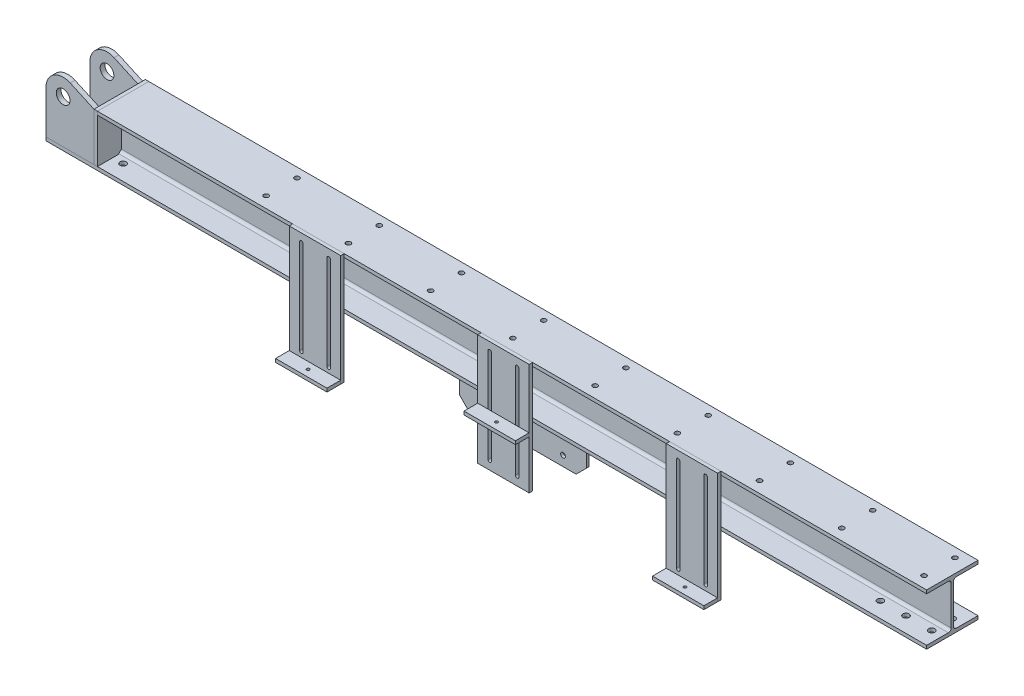
from build123d import *

# Parameters (mm, degrees)
H_HW150_1_DEPTH              = 2570
CUT_EXTRUDE_2_REACH          = 2577.466
SKETCH_18_R                  = 9
SKETCH_19_W                  = 370
SKETCH_19_H                  = 8
EXTRUDE_3_DEPTH              = 140
CHAMFER_1_SIZE               = 30
SKETCH_20_R                  = 7
CUT_EXTRUDE_3_DEPTH          = 8
CUT_EXTRUDE_4_DEPTH          = 75
EXTRUDE_4_DEPTH              = 10
EXTRUDE_5_DEPTH              = 14
EXTRUDE_6_DEPTH              = 14
SKETCH_116_R                 = 20
CUT_EXTRUDE_5_DEPTH          = 14
SKETCH_117_R                 = 20
CUT_EXTRUDE_6_DEPTH          = 14
EXTRUDE_7_DEPTH              = 6
PATTERN_LINEAR_1_COUNT       = 4
PATTERN_LINEAR_1_PITCH       = 570
SKETCH_119_R                 = 7
CUT_EXTRUDE_7_DEPTH          = 10
SKETCH_120_W                 = 150
SKETCH_120_H                 = 325
EXTRUDE_8_DEPTH              = 10
PATTERN_LINEAR_2_COUNT       = 3
PATTERN_LINEAR_2_PITCH       = 550
SKETCH_121_W                 = 150
SKETCH_121_H                 = 10
EXTRUDE_9_DEPTH              = 40
SKETCH_122_W                 = 150
SKETCH_122_H                 = 10
EXTRUDE_10_DEPTH             = 40
SKETCH_123_W                 = 150
SKETCH_123_H                 = 10
EXTRUDE_11_DEPTH             = 40
EXTRUDE_12_DEPTH             = 3
PATTERN_LINEAR_3_COUNT       = 3
PATTERN_LINEAR_3_PITCH       = 550
SKETCH_125_W                 = 4.25
SKETCH_125_H                 = 10.001
SKETCH_126_W                 = 4.25
SKETCH_126_H                 = 10.001
HOLE_WIZARD_M10_2_AT_2_COUNT = 2
HOLE_WIZARD_M10_2_AT_2_PITCH = 1100


with BuildPart() as part:
    # 草图111 → H型钢 HW150(1) (new body)
    with BuildSketch(Plane(origin=(0, 0, 0), x_dir=(0, 0, -1), z_dir=(1, 0, 0))):
        with BuildLine():
            Line((-75, -75), (75, -75))
            Line((75, -75), (75, -65))
            Line((75, -65), (11.5, -65))
            ThreePointArc((11.5, -65), (5.843145751, -62.656854249), (3.5, -57))
            Line((3.5, -57), (3.5, 57))
            ThreePointArc((3.5, 57), (5.843145751, 62.656854249), (11.5, 65))
            Line((11.5, 65), (75, 65))
            Line((75, 65), (75, 75))
            Line((75, 75), (-75, 75))
            Line((-75, 75), (-75, 65))
            Line((-75, 65), (-11.5, 65))
            ThreePointArc((-11.5, 65), (-5.843145751, 62.656854249), (-3.5, 57))
            Line((-3.5, 57), (-3.5, -57))
            ThreePointArc((-3.5, -57), (-5.843145751, -62.656854249), (-11.5, -65))
            Line((-11.5, -65), (-75, -65))
            Line((-75, -65), (-75, -75))
        make_face()
    extrude(amount=H_HW150_1_DEPTH)

    # 草图18 → 切除-拉伸2 (cut, up to next)
    with BuildSketch(Plane.XZ.offset(75), mode=Mode.PRIVATE) as cut_extrude_2_sk1:
        with Locations(Location((30, 30, 0), (0, 0, 270))):
            Circle(SKETCH_18_R)
    cut_extrude_2_tool1 = extrude(cut_extrude_2_sk1.sketch, amount=-CUT_EXTRUDE_2_REACH, mode=Mode.PRIVATE) & part.part
    # 草图18 → 切除-拉伸2 (cut, up to next)
    with BuildSketch(Plane.XZ.offset(75), mode=Mode.PRIVATE) as cut_extrude_2_sk2:
        with Locations(Location((30, -30, 0), (0, 0, 270))):
            Circle(SKETCH_18_R)
    cut_extrude_2_tool2 = extrude(cut_extrude_2_sk2.sketch, amount=-CUT_EXTRUDE_2_REACH, mode=Mode.PRIVATE) & part.part
    # 草图18 → 切除-拉伸2 (cut, up to next)
    with BuildSketch(Plane.XZ.offset(75), mode=Mode.PRIVATE) as cut_extrude_2_sk3:
        with Locations(Location((105, -30, 0), (0, 0, 270))):
            Circle(SKETCH_18_R)
    cut_extrude_2_tool3 = extrude(cut_extrude_2_sk3.sketch, amount=-CUT_EXTRUDE_2_REACH, mode=Mode.PRIVATE) & part.part
    # 草图18 → 切除-拉伸2 (cut, up to next)
    with BuildSketch(Plane.XZ.offset(75), mode=Mode.PRIVATE) as cut_extrude_2_sk4:
        with Locations(Location((105, 30, 0), (0, 0, 270))):
            Circle(SKETCH_18_R)
    cut_extrude_2_tool4 = extrude(cut_extrude_2_sk4.sketch, amount=-CUT_EXTRUDE_2_REACH, mode=Mode.PRIVATE) & part.part
    # 草图18 → 切除-拉伸2 (cut, up to next)
    with BuildSketch(Plane.XZ.offset(75), mode=Mode.PRIVATE) as cut_extrude_2_sk5:
        with Locations(Location((180, 30, 0), (0, 0, 270))):
            Circle(SKETCH_18_R)
    cut_extrude_2_tool5 = extrude(cut_extrude_2_sk5.sketch, amount=-CUT_EXTRUDE_2_REACH, mode=Mode.PRIVATE) & part.part
    # 草图18 → 切除-拉伸2 (cut, up to next)
    with BuildSketch(Plane.XZ.offset(75), mode=Mode.PRIVATE) as cut_extrude_2_sk6:
        with Locations(Location((180, -30, 0), (0, 0, 270))):
            Circle(SKETCH_18_R)
    cut_extrude_2_tool6 = extrude(cut_extrude_2_sk6.sketch, amount=-CUT_EXTRUDE_2_REACH, mode=Mode.PRIVATE) & part.part
    # 草图18 → 切除-拉伸2 (cut, up to next)
    with BuildSketch(Plane.XZ.offset(75), mode=Mode.PRIVATE) as cut_extrude_2_sk7:
        with Locations(Location((2390, 30, 0), (0, 0, 270))):
            Circle(SKETCH_18_R)
    cut_extrude_2_tool7 = extrude(cut_extrude_2_sk7.sketch, amount=-CUT_EXTRUDE_2_REACH, mode=Mode.PRIVATE) & part.part
    # 草图18 → 切除-拉伸2 (cut, up to next)
    with BuildSketch(Plane.XZ.offset(75), mode=Mode.PRIVATE) as cut_extrude_2_sk8:
        with Locations(Location((2465, 30, 0), (0, 0, 270))):
            Circle(SKETCH_18_R)
    cut_extrude_2_tool8 = extrude(cut_extrude_2_sk8.sketch, amount=-CUT_EXTRUDE_2_REACH, mode=Mode.PRIVATE) & part.part
    # 草图18 → 切除-拉伸2 (cut, up to next)
    with BuildSketch(Plane.XZ.offset(75), mode=Mode.PRIVATE) as cut_extrude_2_sk9:
        with Locations(Location((2540, 30, 0), (0, 0, 270))):
            Circle(SKETCH_18_R)
    cut_extrude_2_tool9 = extrude(cut_extrude_2_sk9.sketch, amount=-CUT_EXTRUDE_2_REACH, mode=Mode.PRIVATE) & part.part
    # 草图18 → 切除-拉伸2 (cut, up to next)
    with BuildSketch(Plane.XZ.offset(75), mode=Mode.PRIVATE) as cut_extrude_2_sk10:
        with Locations(Location((2540, -30, 0), (0, 0, 270))):
            Circle(SKETCH_18_R)
    cut_extrude_2_tool10 = extrude(cut_extrude_2_sk10.sketch, amount=-CUT_EXTRUDE_2_REACH, mode=Mode.PRIVATE) & part.part
    # 草图18 → 切除-拉伸2 (cut, up to next)
    with BuildSketch(Plane.XZ.offset(75), mode=Mode.PRIVATE) as cut_extrude_2_sk11:
        with Locations(Location((2465, -30, 0), (0, 0, 270))):
            Circle(SKETCH_18_R)
    cut_extrude_2_tool11 = extrude(cut_extrude_2_sk11.sketch, amount=-CUT_EXTRUDE_2_REACH, mode=Mode.PRIVATE) & part.part
    # 草图18 → 切除-拉伸2 (cut, up to next)
    with BuildSketch(Plane.XZ.offset(75), mode=Mode.PRIVATE) as cut_extrude_2_sk12:
        with Locations(Location((2390, -30, 0), (0, 0, 270))):
            Circle(SKETCH_18_R)
    cut_extrude_2_tool12 = extrude(cut_extrude_2_sk12.sketch, amount=-CUT_EXTRUDE_2_REACH, mode=Mode.PRIVATE) & part.part
    add(cut_extrude_2_tool1.solids().sort_by_distance((30, -75, 30))[0], mode=Mode.SUBTRACT)
    add(cut_extrude_2_tool2.solids().sort_by_distance((30, -75, -30))[0], mode=Mode.SUBTRACT)
    add(cut_extrude_2_tool3.solids().sort_by_distance((105, -75, -30))[0], mode=Mode.SUBTRACT)
    add(cut_extrude_2_tool4.solids().sort_by_distance((105, -75, 30))[0], mode=Mode.SUBTRACT)
    add(cut_extrude_2_tool5.solids().sort_by_distance((180, -75, 30))[0], mode=Mode.SUBTRACT)
    add(cut_extrude_2_tool6.solids().sort_by_distance((180, -75, -30))[0], mode=Mode.SUBTRACT)
    add(cut_extrude_2_tool7.solids().sort_by_distance((2390, -75, 30))[0], mode=Mode.SUBTRACT)
    add(cut_extrude_2_tool8.solids().sort_by_distance((2465, -75, 30))[0], mode=Mode.SUBTRACT)
    add(cut_extrude_2_tool9.solids().sort_by_distance((2540, -75, 30))[0], mode=Mode.SUBTRACT)
    add(cut_extrude_2_tool10.solids().sort_by_distance((2540, -75, -30))[0], mode=Mode.SUBTRACT)
    add(cut_extrude_2_tool11.solids().sort_by_distance((2465, -75, -30))[0], mode=Mode.SUBTRACT)
    add(cut_extrude_2_tool12.solids().sort_by_distance((2390, -75, -30))[0], mode=Mode.SUBTRACT)

    # 草图112 → 切除-拉伸4 (cut, symmetric)
    with BuildSketch(Plane.XY):
        Polygon((0, 75), (150, 75), (150, 60), (10, -65), (0, -65), align=None)
    extrude(amount=CUT_EXTRUDE_4_DEPTH, both=True, mode=Mode.SUBTRACT)

    # 草图119 → 切除-拉伸7 (cut)
    with BuildSketch(Plane(origin=(0, 75, 0), x_dir=(1, 0, 0), z_dir=(0, 1, 0))):
        with Locations(Location((2530, -42.5, 0), (0, 0, 270))):
            Circle(SKETCH_119_R)
        with Locations(Location((2530, 47.5, 0), (0, 0, 270))):
            Circle(SKETCH_119_R)
        with Locations(Location((2290, -42.5, 0), (0, 0, 270))):
            Circle(SKETCH_119_R)
        with Locations(Location((2290, 47.5, 0), (0, 0, 270))):
            Circle(SKETCH_119_R)
        with Locations(Location((2050, -42.5, 0), (0, 0, 270))):
            Circle(SKETCH_119_R)
        with Locations(Location((2050, 47.5, 0), (0, 0, 270))):
            Circle(SKETCH_119_R)
        with Locations(Location((1810, -42.5, 0), (0, 0, 270))):
            Circle(SKETCH_119_R)
        with Locations(Location((1810, 47.5, 0), (0, 0, 270))):
            Circle(SKETCH_119_R)
        with Locations(Location((1570, -42.5, 0), (0, 0, 270))):
            Circle(SKETCH_119_R)
        with Locations(Location((1570, 47.5, 0), (0, 0, 270))):
            Circle(SKETCH_119_R)
        with Locations(Location((1330, -42.5, 0), (0, 0, 270))):
            Circle(SKETCH_119_R)
        with Locations(Location((1330, 47.5, 0), (0, 0, 270))):
            Circle(SKETCH_119_R)
        with Locations(Location((1090, -42.5, 0), (0, 0, 270))):
            Circle(SKETCH_119_R)
        with Locations(Location((1090, 47.5, 0), (0, 0, 270))):
            Circle(SKETCH_119_R)
        with Locations(Location((850, -42.5, 0), (0, 0, 270))):
            Circle(SKETCH_119_R)
        with Locations(Location((850, 47.5, 0), (0, 0, 270))):
            Circle(SKETCH_119_R)
        with Locations(Location((610, -42.5, 0), (0, 0, 270))):
            Circle(SKETCH_119_R)
        with Locations(Location((610, 47.5, 0), (0, 0, 270))):
            Circle(SKETCH_119_R)
    extrude(amount=-CUT_EXTRUDE_7_DEPTH, mode=Mode.SUBTRACT)


with BuildPart() as body_2:
    # 草图19 → 凸台-拉伸3 (new body)
    with BuildSketch(Plane.XZ.offset(75)):
        with Locations((1321, 0)):
            Rectangle(SKETCH_19_W, SKETCH_19_H)
    extrude(amount=EXTRUDE_3_DEPTH)

    # 倒角1
    chamfer_1_edges = [body_2.edges().sort_by_distance(p)[0] for p in [
        (1506, -215, 0),
        (1136, -215, 0),
    ]]
    chamfer(chamfer_1_edges, length=CHAMFER_1_SIZE)

    # 草图20 → 切除-拉伸3 (cut)
    with BuildSketch(Plane(origin=(0, 0, -4), x_dir=(-1, 0, 0), z_dir=(0, 0, -1))):
        with Locations(Location((-1401, -115, 0), (0, 0, 90))):
            Circle(SKETCH_20_R)
        with Locations(Location((-1241, -115, 0), (0, 0, 90))):
            Circle(SKETCH_20_R)
        with Locations(Location((-1437.939889059, -185.960866654, 0), (0, 0, 90))):
            Circle(SKETCH_20_R)
        with Locations(Location((-1204.060110941, -185.960866654, 0), (0, 0, 90))):
            Circle(SKETCH_20_R)
    extrude(amount=-CUT_EXTRUDE_3_DEPTH, mode=Mode.SUBTRACT)


with BuildPart() as body_3:
    # 草图113 → 凸台-拉伸4 (new body)
    with BuildSketch(Plane.ZY.offset(-150)):
        Polygon((-75, 75), (75, 75), (75, -65), (14, -65), (4, -55), (4, 60.5), (-4, 60.5), (-4, -55), (-14, -65), (-75, -65), align=None)
    extrude(amount=EXTRUDE_4_DEPTH)


with BuildPart() as body_4:
    # 草图114 → 凸台-拉伸5 (new body)
    with BuildSketch(Plane.XY.offset(75)):
        with BuildLine():
            Line((0, -65), (0, 61))
            ThreePointArc((0, 61), (22.934192483, 103.040956976), (70.697682537, 106.514897974))
            Line((70.697682537, 106.514897974), (140, 75))
            Line((140, 75), (140, -65))
            Line((140, -65), (0, -65))
        make_face()
    extrude(amount=-EXTRUDE_5_DEPTH)

    # 草图116 → 切除-拉伸5 (cut)
    with BuildSketch(Plane.XY.offset(75)):
        with Locations((50, 61.5)):
            Circle(SKETCH_116_R)
    extrude(amount=-CUT_EXTRUDE_5_DEPTH, mode=Mode.SUBTRACT)


with BuildPart() as body_5:
    # 草图115 → 凸台-拉伸6 (new body)
    with BuildSketch(Plane(origin=(0, 0, -67), x_dir=(-1, 0, 0), z_dir=(0, 0, -1))):
        with BuildLine():
            Line((-140, -65), (0, -65))
            Line((0, -65), (0, 61))
            ThreePointArc((0, 61), (-22.934192483, 103.040956976), (-70.697682537, 106.514897974))
            Line((-70.697682537, 106.514897974), (-140, 75))
            Line((-140, 75), (-140, -65))
        make_face()
    extrude(amount=-EXTRUDE_6_DEPTH)

    # 草图117 → 切除-拉伸6 (cut)
    with BuildSketch(Plane(origin=(0, 0, -67), x_dir=(-1, 0, 0), z_dir=(0, 0, -1))):
        with Locations((-50, 61)):
            Circle(SKETCH_117_R)
    extrude(amount=-CUT_EXTRUDE_6_DEPTH, mode=Mode.SUBTRACT)


with BuildPart() as body_6:
    # 草图118 → 凸台-拉伸7 (new body)
    with BuildSketch(Plane(origin=(2420, 0, 0), x_dir=(0, 0, -1), z_dir=(1, 0, 0))):
        Polygon((13.5, 65), (73.5, 65), (73.5, -65), (13.5, -65), (3.5, -55), (3.5, 55), align=None)
    extrude_7 = extrude(amount=EXTRUDE_7_DEPTH)


with BuildPart() as pattern_linear_1_1:
    # 阵列(线性)1: 凸台-拉伸7 ×4
    with Locations(*[(-i * PATTERN_LINEAR_1_PITCH, 0, 0) for i in range(1, PATTERN_LINEAR_1_COUNT)]):
        add(extrude_7)


with BuildPart() as body_10:
    # 草图120 → 凸台-拉伸8 (new body)
    with BuildSketch(Plane.XY.offset(75)):
        with Locations((1895, -87.5)):
            Rectangle(SKETCH_120_W, SKETCH_120_H)
        with BuildLine():
            Line((1850, -225), (1850, 50))
            ThreePointArc((1850, 50), (1855, 55), (1860, 50))
            Line((1860, 50), (1860, -225))
            ThreePointArc((1860, -225), (1855, -230), (1850, -225))
        make_face(mode=Mode.SUBTRACT)
        with BuildLine():
            Line((1930, 50), (1930, -225))
            ThreePointArc((1930, -225), (1935, -230), (1940, -225))
            Line((1940, -225), (1940, 50))
            ThreePointArc((1940, 50), (1935, 55), (1930, 50))
        make_face(mode=Mode.SUBTRACT)
    extrude_8 = extrude(amount=EXTRUDE_8_DEPTH)


with BuildPart() as pattern_linear_2_1:
    # 阵列(线性)2: 凸台-拉伸8 ×3
    with Locations(*[(-i * PATTERN_LINEAR_2_PITCH, 0, 0) for i in range(1, PATTERN_LINEAR_2_COUNT)]):
        add(extrude_8)


with BuildPart() as body_13:
    # 草图121 → 凸台-拉伸9 (new body)
    with BuildSketch(Plane.XY.offset(85)):
        with Locations((795, -245)):
            Rectangle(SKETCH_121_W, SKETCH_121_H)
    extrude(amount=EXTRUDE_9_DEPTH)

    # 草图126 → M10 螺纹孔2 (revolve, cut)
    with BuildSketch(Plane(origin=(795, -240, 105), x_dir=(0, 0, 1), z_dir=(1, 0, 0))):
        with Locations((2.125, 5.0005)):
            Rectangle(SKETCH_126_W, SKETCH_126_H)
    hole_wizard_m10_2 = revolve(axis=Axis((795, -233.65, 105), (0, -1, 0)), mode=Mode.SUBTRACT)


with BuildPart() as body_14:
    # 草图122 → 凸台-拉伸10 (new body)
    with BuildSketch(Plane.XY.offset(85)):
        with Locations((1345, -103)):
            Rectangle(SKETCH_122_W, SKETCH_122_H)
    extrude(amount=EXTRUDE_10_DEPTH)

    # 草图125 → M10 螺纹孔1 (revolve, cut)
    with BuildSketch(Plane(origin=(1345, -108, 105), x_dir=(0, 0, -1), z_dir=(1, 0, 0))):
        with Locations((2.125, 5.0005)):
            Rectangle(SKETCH_125_W, SKETCH_125_H)
    revolve(axis=Axis((1345, -114.35, 105), (0, 1, 0)), mode=Mode.SUBTRACT)


with BuildPart() as body_15:
    # 草图123 → 凸台-拉伸11 (new body)
    with BuildSketch(Plane.XY.offset(85)):
        with Locations((1895, -245)):
            Rectangle(SKETCH_123_W, SKETCH_123_H)
    extrude(amount=EXTRUDE_11_DEPTH)

    # M10 螺纹孔2 at 2: M10 螺纹孔2 ×2
    with Locations(*[(i * HOLE_WIZARD_M10_2_AT_2_PITCH, 0, 0) for i in range(1, HOLE_WIZARD_M10_2_AT_2_COUNT)]):
        add(hole_wizard_m10_2, mode=Mode.SUBTRACT)


with BuildPart() as body_16:
    # 草图124 → 凸台-拉伸12 (new, symmetric)
    with BuildSketch(Plane.ZY.offset(-795)):
        Polygon((65, -75), (75, -85), (75, -250), (65, -250), (4, -95), (4, -85), (14, -75), align=None)
    extrude_12 = extrude(amount=EXTRUDE_12_DEPTH, both=True)


with BuildPart() as pattern_linear_3_1:
    # 阵列(线性)3: 凸台-拉伸12 ×3
    with Locations(*[(i * PATTERN_LINEAR_3_PITCH, 0, 0) for i in range(1, PATTERN_LINEAR_3_COUNT)]):
        add(extrude_12)


solid = Compound([part.part, body_2.part, body_3.part, body_4.part, body_5.part, body_6.part, pattern_linear_1_1.part, body_10.part, pattern_linear_2_1.part, body_13.part, body_14.part, body_15.part, body_16.part, pattern_linear_3_1.part])
